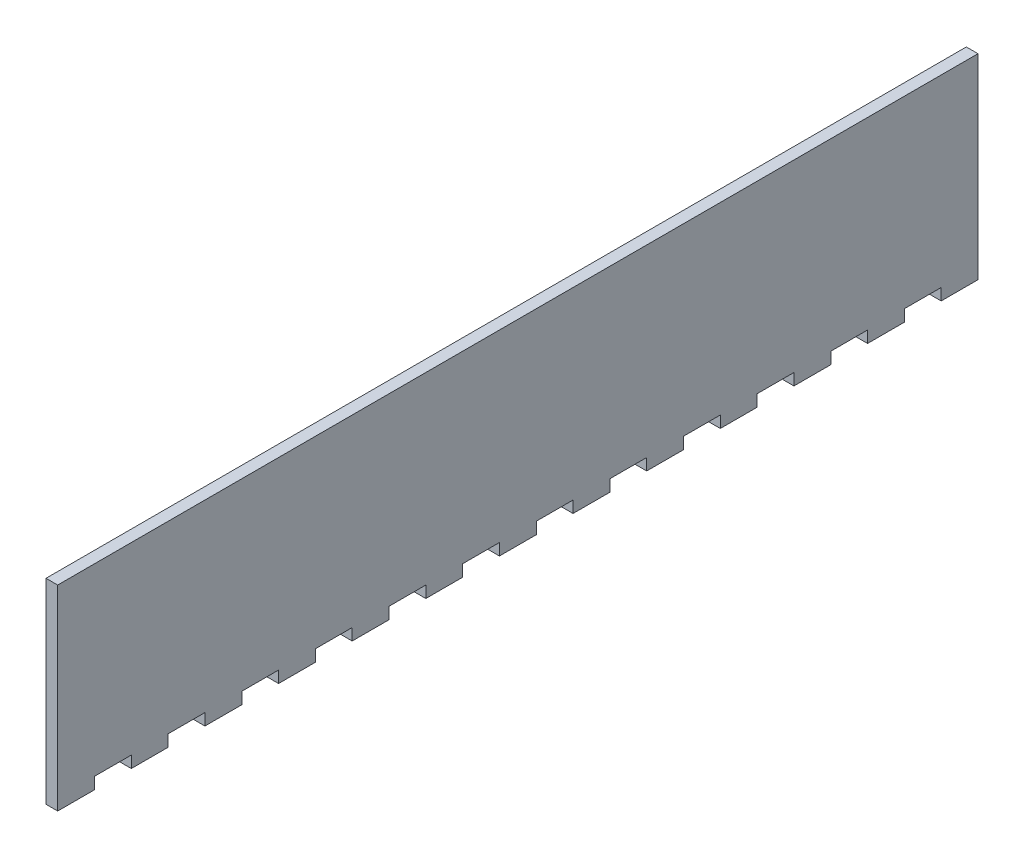
from build123d import *

# Parameters (mm, degrees)
ESQUISSE2_W                = 250
ESQUISSE2_H                = 50
BOSS_EXTRU_1_DEPTH         = 3.175
ESQUISSE3_W                = 10
ESQUISSE3_H                = 3.175
BOSS_EXTRU_2_DEPTH         = 3.175
R_P_TITION_LIN_AIRE1_COUNT = 13
R_P_TITION_LIN_AIRE1_PITCH = 20


with BuildPart() as part:
    # Esquisse2 → Boss.-Extru.1 (new body)
    with BuildSketch(Plane(origin=(0, 0, 0), x_dir=(0, 0, -1), z_dir=(1, 0, 0))):
        with Locations((125, 25)):
            Rectangle(ESQUISSE2_W, ESQUISSE2_H)
    extrude(amount=BOSS_EXTRU_1_DEPTH)

    # Esquisse3 → Boss.-Extru.2 (add)
    with BuildSketch(Plane(origin=(3.175, 0, 0), x_dir=(0, 0, -1), z_dir=(1, 0, 0))):
        with Locations((5, -1.5875)):
            Rectangle(ESQUISSE3_W, ESQUISSE3_H)
    boss_extru_2 = extrude(amount=-BOSS_EXTRU_2_DEPTH)

    # Répétition linéaire1: Boss.-Extru.2 ×13
    with Locations(*[(0, 0, -i * R_P_TITION_LIN_AIRE1_PITCH) for i in range(1, R_P_TITION_LIN_AIRE1_COUNT)]):
        add(boss_extru_2)


solid = part.part
